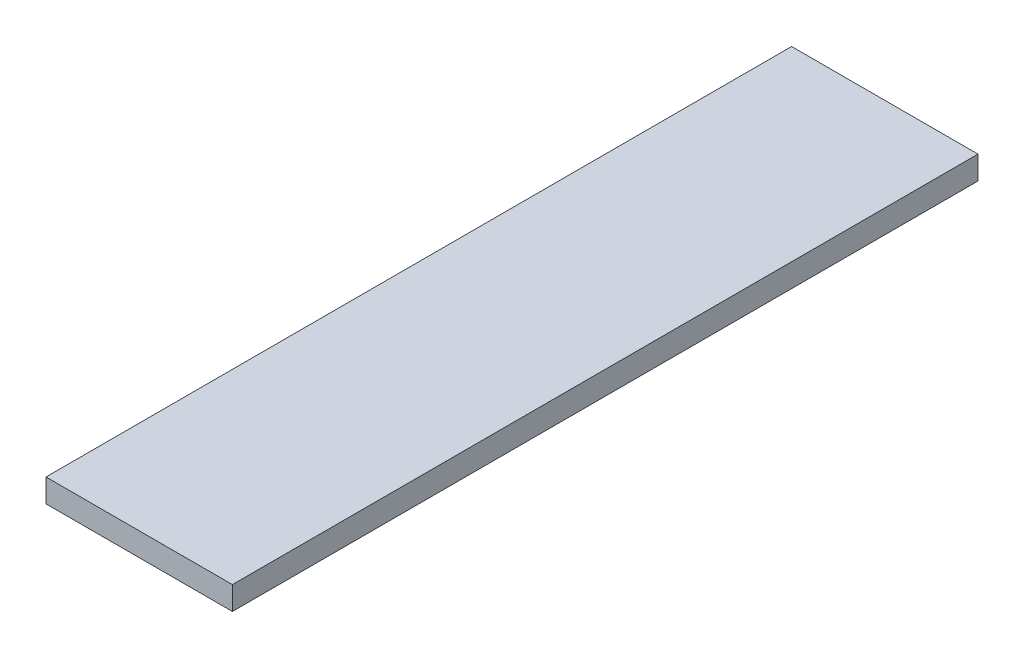
from build123d import *

# Parameters (mm, degrees)
SKETCH1_W           = 25.4
SKETCH1_H           = 101.6
BOSS_EXTRUDE1_DEPTH = 3.175


with BuildPart() as part:
    # Sketch1 → Boss-Extrude1 (new body)
    with BuildSketch(Plane(origin=(0, 0, 0), x_dir=(1, 0, 0), z_dir=(0, 1, 0))):
        with Locations((12.7, 50.8)):
            Rectangle(SKETCH1_W, SKETCH1_H)
    extrude(amount=BOSS_EXTRUDE1_DEPTH)


solid = part.part
